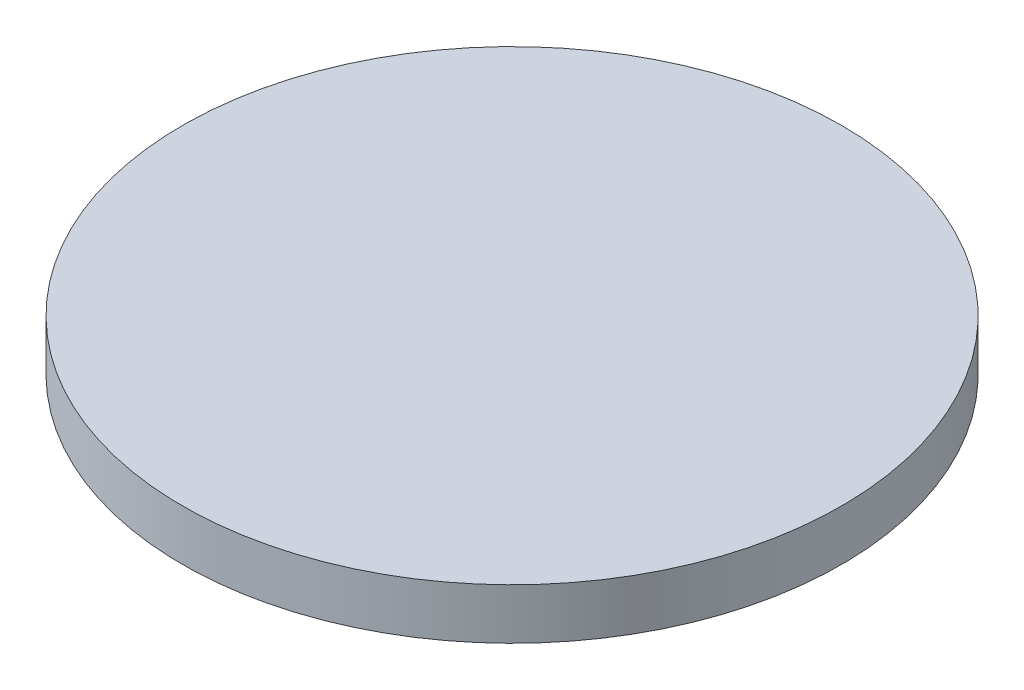
from build123d import *


with BuildPart() as part:
    # Sketch1 → Revolve1 (revolve)
    with BuildSketch(Plane.XY):
        Polygon((0, 0), (0, 15), (32.5, 15), (32.5, 10), (12.5, 0), align=None)
    revolve(axis=Axis((0, 0, 0), (0, 1, 0)))


solid = part.part
